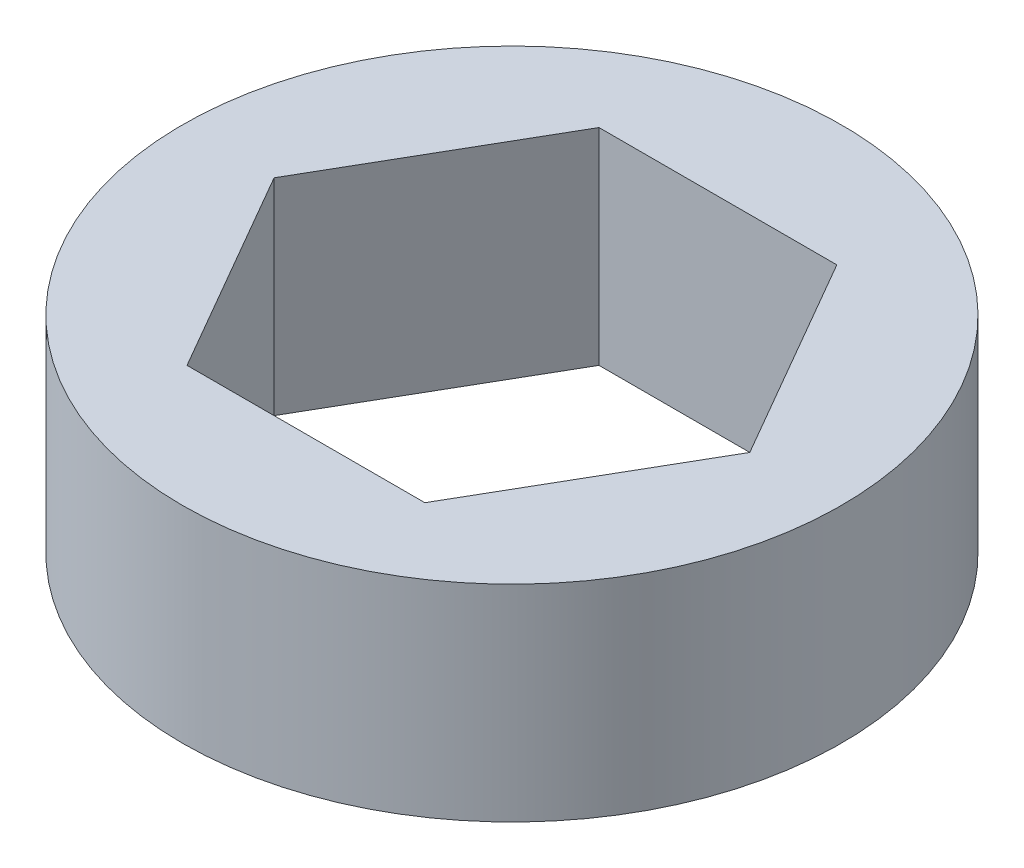
from build123d import *

# Parameters (mm, degrees)
SKETCH1_R           = 10.16
BOSS_EXTRUDE1_DEPTH = 6.35


with BuildPart() as part:
    # Sketch1 → Boss-Extrude1 (new body)
    with BuildSketch(Plane(origin=(0, 0, 0), x_dir=(1, 0, 0), z_dir=(0, 1, 0))):
        Circle(SKETCH1_R)
        Polygon((7.332348419, 0), (3.666174209, 6.35), (-3.666174209, 6.35), (-7.332348419, 0), (-3.666174209, -6.35), (3.666174209, -6.35), align=None, mode=Mode.SUBTRACT)
    extrude(amount=BOSS_EXTRUDE1_DEPTH)


solid = part.part
